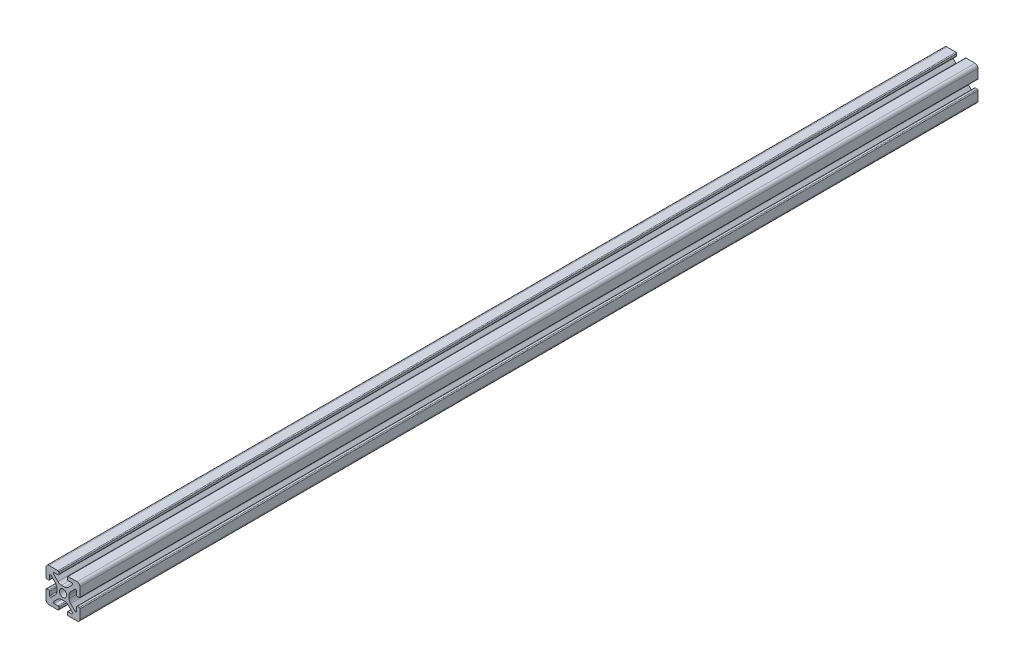
from build123d import *

# Parameters (mm, degrees)
BOSS_EXTRUDE1_DEPTH = 264


with BuildPart() as part:
    # Sketch4 → Boss-Extrude1 (new body, symmetric)
    with BuildSketch(Plane.XY):
        with BuildLine():
            Line((3, -10), (8.25, -10))
            ThreePointArc((8.25, -10), (9.487436867, -9.487436867), (10, -8.25))
            Line((10, -8.25), (10, -3))
            ThreePointArc((10, -3), (9.853553391, -2.646446609), (9.5, -2.5))
            Line((9.5, -2.5), (8.424621202, -2.5))
            ThreePointArc((8.424621202, -2.5), (8.071067812, -2.646446609), (7.924621202, -3))
            Line((7.924621202, -3), (7.924621202, -5.25))
            ThreePointArc((7.924621202, -5.25), (7.615962919, -5.711939766), (7.071067812, -5.603553391))
            Line((7.071067812, -5.603553391), (4.478679656, -3.011165235))
            ThreePointArc((4.478679656, -3.011165235), (3.828361402, -2.037895189), (3.6, -0.889844892))
            Line((3.6, -0.889844892), (3.6, 0))
            Line((3.6, 0), (2.15, 0))
            ThreePointArc((2.15, 0), (1.52027958, -1.52027958), (0, -2.15))
            Line((0, -2.15), (0, -3.6))
            Line((0, -3.6), (0.889844892, -3.6))
            ThreePointArc((0.889844892, -3.6), (2.037895189, -3.828361402), (3.011165235, -4.478679656))
            Line((3.011165235, -4.478679656), (5.603553391, -7.071067812))
            ThreePointArc((5.603553391, -7.071067812), (5.711939766, -7.615962919), (5.25, -7.924621202))
            Line((5.25, -7.924621202), (3, -7.924621202))
            ThreePointArc((3, -7.924621202), (2.646446609, -8.071067812), (2.5, -8.424621202))
            Line((2.5, -8.424621202), (2.5, -9.5))
            ThreePointArc((2.5, -9.5), (2.646446609, -9.853553391), (3, -10))
        make_face()
    extrude(amount=BOSS_EXTRUDE1_DEPTH, both=True)

    # Mirror1: part across plane


with BuildPart() as part_1:
    add(part.part)
    add(part.part.mirror(Plane(origin=(0, 0, 0), x_dir=(0, 0, 1), z_dir=(1, 0, 0))))

    # Mirror2: part across plane


with BuildPart() as part_2:
    add(part_1.part)
    add(part_1.part.mirror(Plane.ZX))


solid = part_2.part
